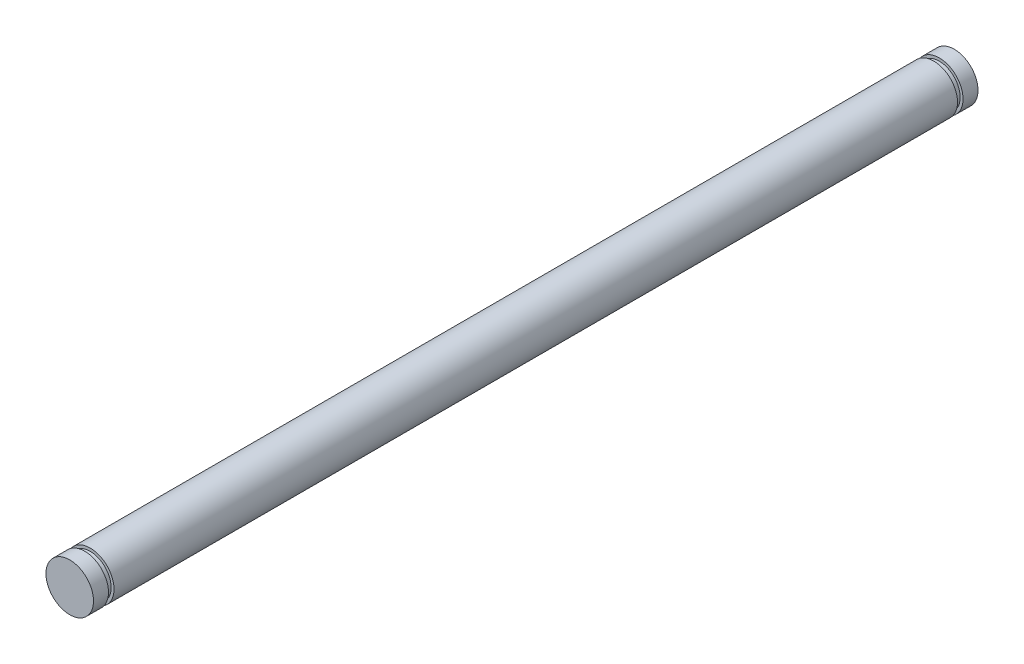
from build123d import *

# Parameters (mm, degrees)
SKETCH2_R           = 3.175
BOSS_EXTRUDE1_DEPTH = 56.32
SKETCH3_R           = 2.794
BOSS_EXTRUDE2_DEPTH = 0.7366
SKETCH4_R           = 3.175
BOSS_EXTRUDE3_DEPTH = 2


with BuildPart() as part:
    # Sketch2 → Boss-Extrude1 (new body)
    with BuildSketch(Plane.XY):
        Circle(SKETCH2_R)
    boss_extrude1 = extrude(amount=BOSS_EXTRUDE1_DEPTH)

    # Sketch3 → Boss-Extrude2 (add)
    with BuildSketch(Plane.XY.offset(56.32)):
        Circle(SKETCH3_R)
    boss_extrude2 = extrude(amount=BOSS_EXTRUDE2_DEPTH)

    # Sketch4 → Boss-Extrude3 (add)
    with BuildSketch(Plane.XY.offset(57.0566)):
        Circle(SKETCH4_R)
    boss_extrude3 = extrude(amount=BOSS_EXTRUDE3_DEPTH)

    # Mirror1: Boss-Extrude1, Boss-Extrude2, Boss-Extrude3 across plane
    add(boss_extrude1.mirror(Plane.XY))
    add(boss_extrude2.mirror(Plane.XY))
    add(boss_extrude3.mirror(Plane.XY))


solid = part.part
